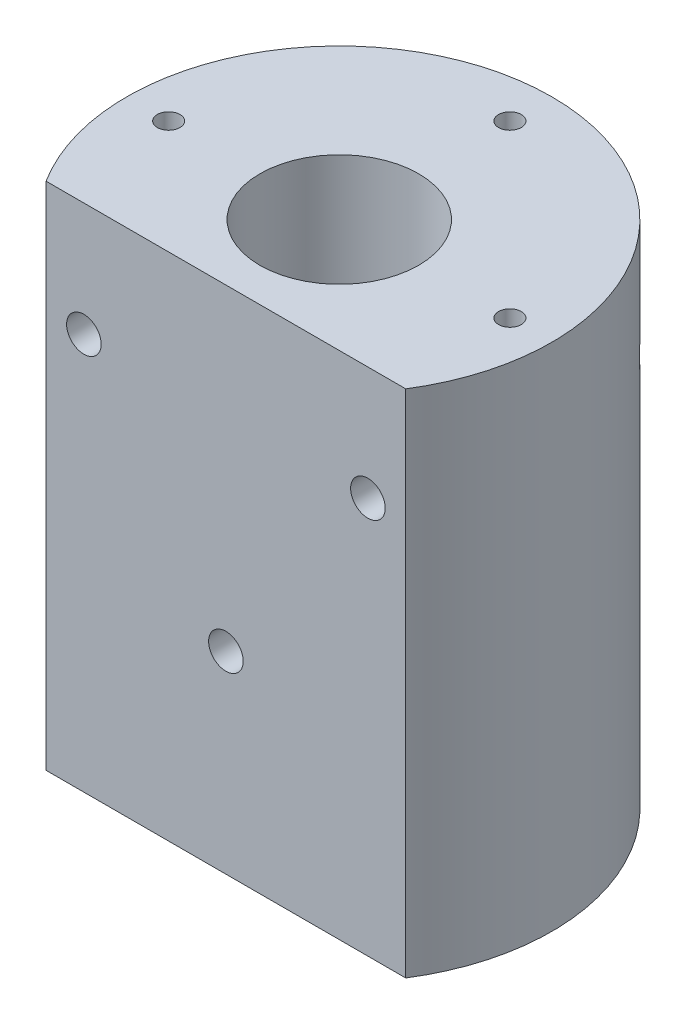
from build123d import *

# Parameters (mm, degrees)
SKETCH1_R             = 11.2
BOSS_EXTRUDE1_DEPTH   = 90
SKETCH1_3_R           = 2
CORTE_EXTRUS_O1_DEPTH = 14.6
SKETCH1_4_R           = 14
SKETCH1_4_R_2         = 11.2
CORTE_EXTRUS_O2_DEPTH = 50
ESBO_O1_R             = 2.5
CORTE_EXTRUS_O3_DEPTH = 23
ESBO_O2_R             = 3.05
CORTE_EXTRUS_O4_DEPTH = 114.192314227
CORTE_EXTRUS_O5_REACH = 115.192


with BuildPart() as part:
    # Sketch1 → Boss-Extrude1 (new body)
    with BuildSketch(Plane(origin=(0, 0, 0), x_dir=(1, 0, 0), z_dir=(0, 1, 0))):
        with BuildLine():
            Line((-31.721443851, -20), (31.721443851, -20))
            ThreePointArc((31.721443851, -20), (0, 37.5), (-31.721443851, -20))
        make_face()
        Circle(SKETCH1_R, mode=Mode.SUBTRACT)
    extrude(amount=-BOSS_EXTRUDE1_DEPTH)

    # Sketch1_3 → Corte-extrus_o1 (cut)
    with BuildSketch(Plane(origin=(0, 0, 0), x_dir=(1, 0, 0), z_dir=(0, 1, 0))):
        with Locations((-30.1, 0)):
            Circle(SKETCH1_3_R)
        with Locations((30.1, 0)):
            Circle(SKETCH1_3_R)
        with Locations((0, 30.1)):
            Circle(SKETCH1_3_R)
    extrude(amount=-CORTE_EXTRUS_O1_DEPTH, mode=Mode.SUBTRACT)

    # Sketch1_4 → Corte-extrus_o2 (cut)
    with BuildSketch(Plane(origin=(0, 0, 0), x_dir=(1, 0, 0), z_dir=(0, 1, 0))):
        Circle(SKETCH1_4_R)
        Circle(SKETCH1_4_R_2, mode=Mode.SUBTRACT)
    extrude(amount=-CORTE_EXTRUS_O2_DEPTH, mode=Mode.SUBTRACT)

    # Esbo_o1 → Corte-extrus_o3 (cut)
    with BuildSketch(Plane.XZ.offset(90)):
        with Locations((-25, 0)):
            Circle(ESBO_O1_R)
        with Locations((25, 0)):
            Circle(ESBO_O1_R)
    extrude(amount=-CORTE_EXTRUS_O3_DEPTH, mode=Mode.SUBTRACT)

    # Esbo_o2 → Corte-extrus_o4 (cut, through all)
    with BuildSketch(Plane.XY.offset(20)):
        with Locations((-25.05, -20.05)):
            Circle(ESBO_O2_R)
        with Locations((25.05, -20.05)):
            Circle(ESBO_O2_R)
    extrude(amount=-CORTE_EXTRUS_O4_DEPTH, mode=Mode.SUBTRACT)

    # Esbo_o2_3 → Corte-extrus_o5 (cut, up to next)
    with BuildSketch(Plane.XY.offset(20), mode=Mode.PRIVATE) as corte_extrus_o5_sk1:
        with BuildLine():
            ThreePointArc((0, -59), (2.156675683, -58.106675683), (3.05, -55.95))
            ThreePointArc((3.05, -55.95), (-2.156675683, -53.793324317), (0, -59))
        make_face()
    corte_extrus_o5_tool1 = extrude(corte_extrus_o5_sk1.sketch, amount=-CORTE_EXTRUS_O5_REACH, mode=Mode.PRIVATE) & part.part
    add(corte_extrus_o5_tool1.solids().sort_by_distance((0, -55.95, 20))[0], mode=Mode.SUBTRACT)


solid = part.part
